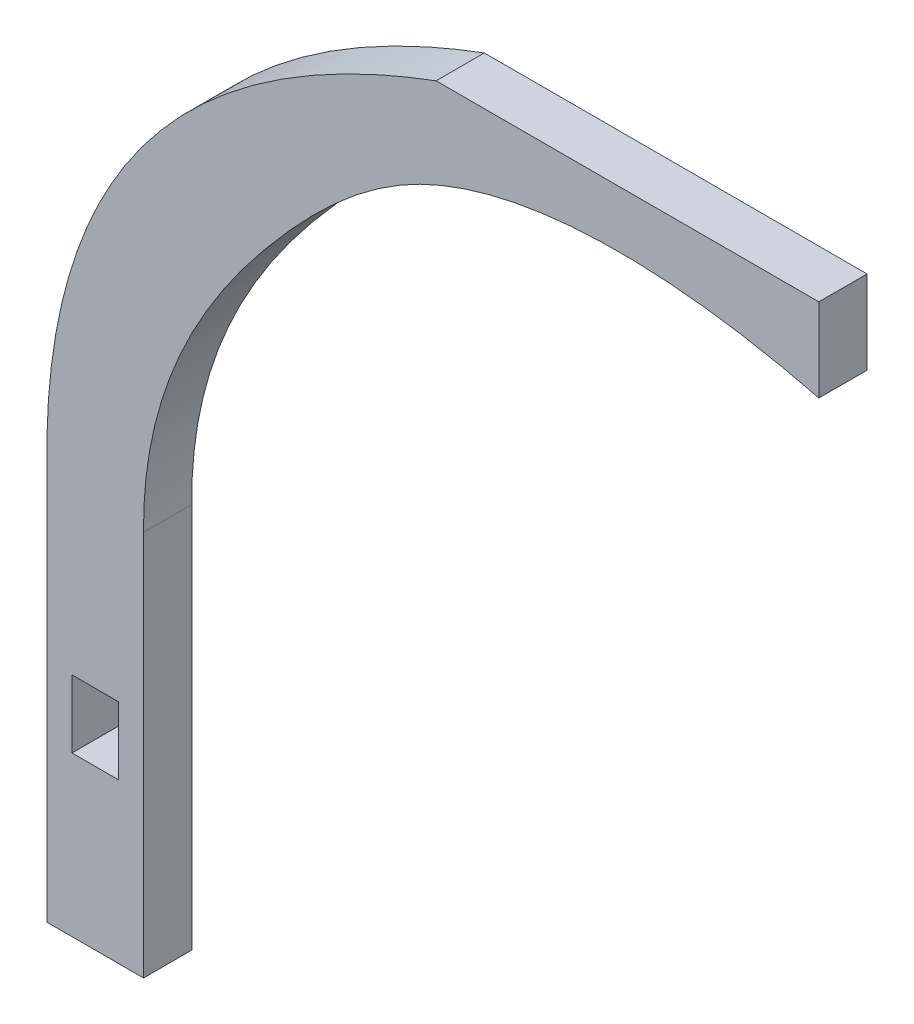
from build123d import *

# Parameters (mm, degrees)
ESQUISSE1_W        = 4.826
ESQUISSE1_H        = 7.0104
BOSS_EXTRU_2_DEPTH = 5


with BuildPart() as part:
    # Esquisse1 → Boss.-Extru.2 (new body)
    with BuildSketch(Plane.XY):
        with BuildLine():
            Line((-5, 20), (-5, -20))
            Line((-5, -20), (5, -20))
            Line((5, -20), (5, 20))
            add(Edge.make_bspline(
                [(75, 67.059484201), (62.03093477, 70.366927919), (38.269649401, 72.406891381), (13.9373301, 49.417587767), (4.875540917, 33.447930614), (5, 20)],
                knots=[0, 0, 0, 0, 0.444260837, 0.615865686, 1, 1, 1, 1], degree=3))
            Line((75, 67.059484201), (75, 75.698795143))
            Line((75, 75.698795143), (35.325749863, 75.698795143))
            add(Edge.make_bspline(
                [(-5, 20), (-6.083057018, 60.379699371), (35.325749863, 75.698795143)],
                knots=[0, 0, 0, 1, 1, 1], degree=2))
        make_face()
        Rectangle(ESQUISSE1_W, ESQUISSE1_H, mode=Mode.SUBTRACT)
    extrude(amount=BOSS_EXTRU_2_DEPTH)


solid = part.part
